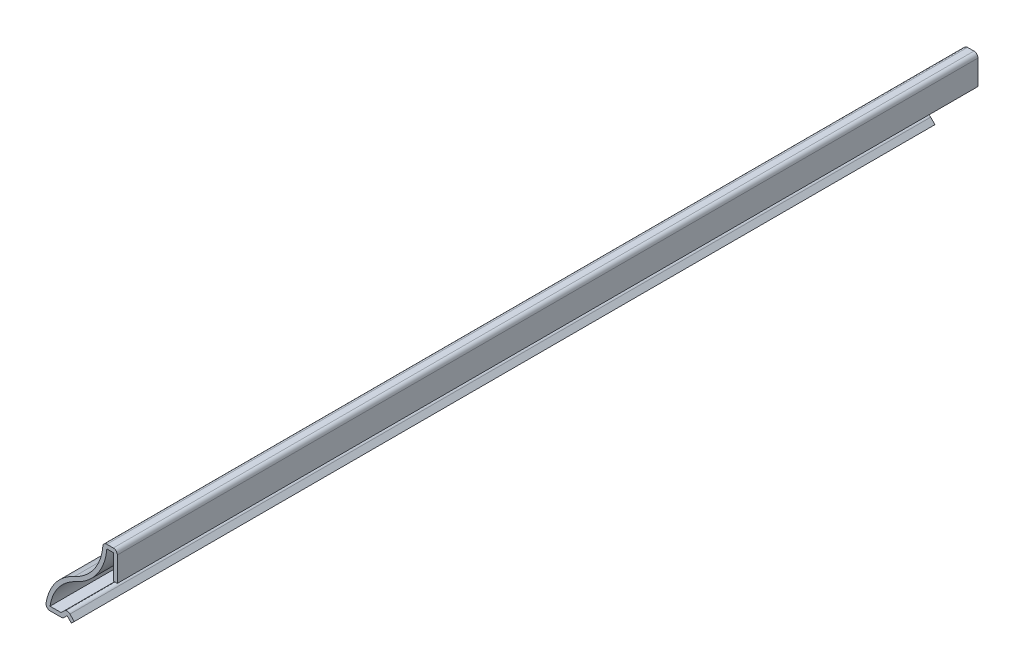
from build123d import *

# Parameters (mm, degrees)
BOSS_EXTRUDE1_DEPTH = 190.5
FILLET1_R           = 0.889


with BuildPart() as part:
    # Sketch1 → Boss-Extrude1 (new body)
    with BuildSketch(Plane.XY):
        with BuildLine():
            Line((0, 0), (-0.958882072, 0.958882072))
            Line((-0.958882072, 0.958882072), (-1.917764143, 0))
            Line((-1.917764143, 0), (-5.721382072, 0))
            ThreePointArc((-5.721382072, 0), (-3.85935029, 5.527652939), (0.622114471, 9.26109411))
            ThreePointArc((0.622114471, 9.26109411), (5.250076185, 13.214166411), (6.978617928, 19.05))
            Line((6.978617928, 19.05), (10.153617928, 19.05))
            Line((10.153617928, 19.05), (10.153617928, 12.7))
            Line((10.153617928, 12.7), (9.264617928, 12.7))
            Line((9.264617928, 12.7), (9.264617928, 18.161))
            Line((9.264617928, 18.161), (7.833515838, 18.161))
            ThreePointArc((7.833515838, 18.161), (5.746261278, 12.361581443), (0.98376011, 8.448977473))
            ThreePointArc((0.98376011, 8.448977473), (-2.851879391, 5.405556737), (-4.74271397, 0.889))
            Line((-4.74271397, 0.889), (-2.286, 0.889))
            Line((-2.286, 0.889), (-0.958882072, 2.216117928))
            Line((-0.958882072, 2.216117928), (0.628617928, 0.628617928))
            Line((0.628617928, 0.628617928), (0, 0))
        make_face()
    extrude(amount=-BOSS_EXTRUDE1_DEPTH)

    # Fillet1
    fillet1_edges = [part.edges().sort_by_distance(p)[0] for p in [
        (-1.917764143, 0, -95.25),
        (-5.721382072, 0, -95.25),
        (6.978617928, 19.05, -95.25),
        (10.153617928, 19.05, -95.25),
        (-0.958882072, 2.216117928, -95.25),
    ]]
    fillet(fillet1_edges, radius=FILLET1_R)


solid = part.part
